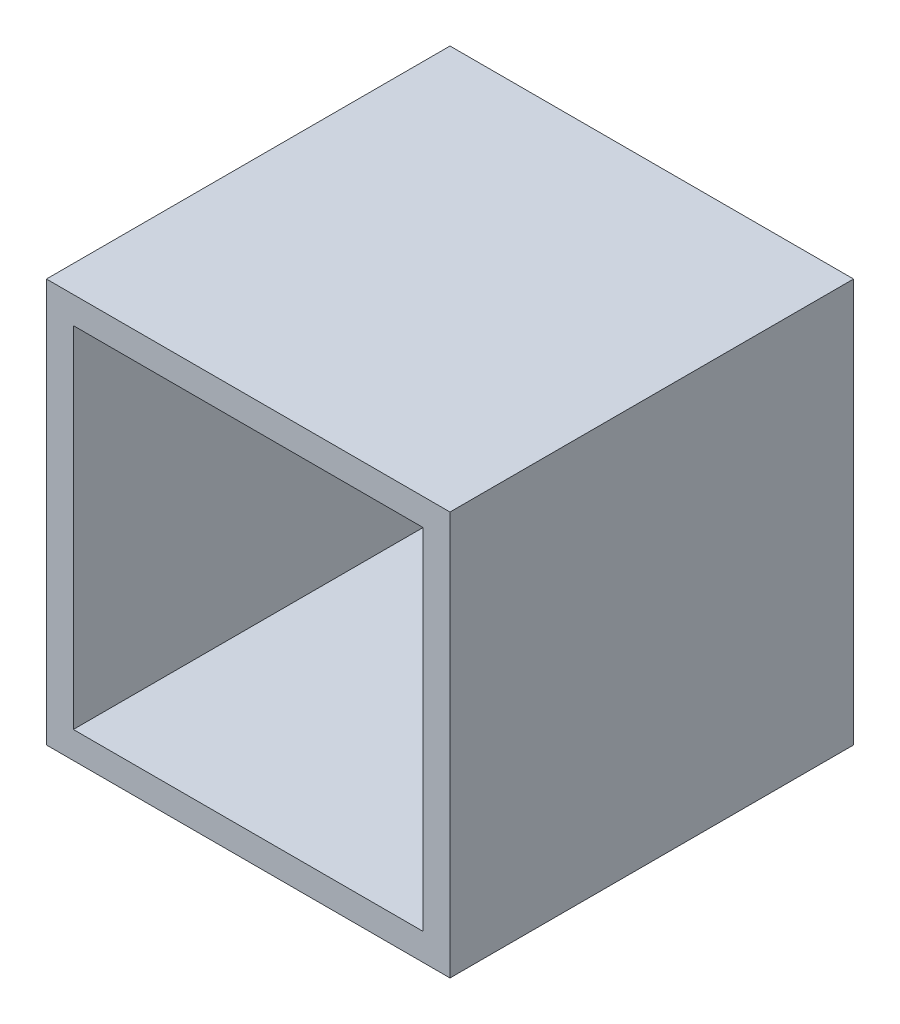
from build123d import *

# Parameters (mm, degrees)
SKETCH1_W           = 150
SKETCH1_H           = 150
BOSS_EXTRUDE1_DEPTH = 150
SKETCH3_W           = 130
SKETCH3_H           = 130
CUT_EXTRUDE1_DEPTH  = 140


with BuildPart() as part:
    # Sketch1 → Boss-Extrude1 (new body)
    with BuildSketch(Plane.XY):
        with Locations((30.654582286, 53.956732077)):
            Rectangle(SKETCH1_W, SKETCH1_H)
    extrude(amount=BOSS_EXTRUDE1_DEPTH)

    # Sketch3 → Cut-Extrude1 (cut)
    with BuildSketch(Plane.XY.offset(150)):
        with Locations((30.654582286, 53.956732077)):
            Rectangle(SKETCH3_W, SKETCH3_H)
    extrude(amount=-CUT_EXTRUDE1_DEPTH, mode=Mode.SUBTRACT)


solid = part.part
